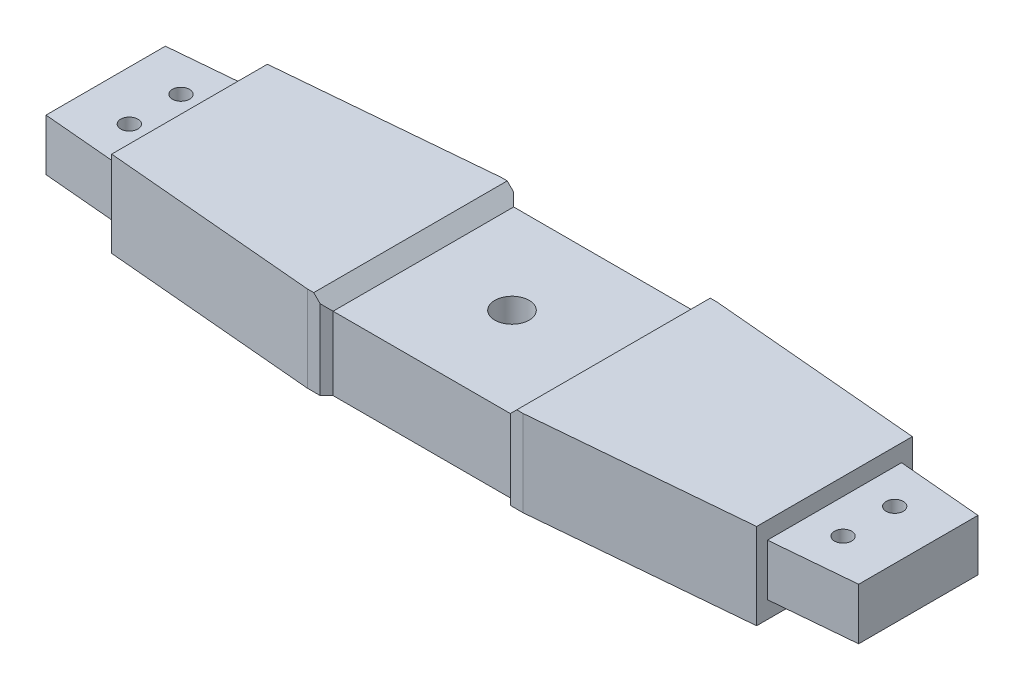
from build123d import *

# Parameters (mm, degrees)
SKETCH1_R                = 4
BOSS_EXTRUDE1_DEPTH      = 12
SKETCH2_R                = 4
BOSS_EXTRUDE2_DEPTH      = 4
BOSS_EXTRUDE2_DEPTH_BACK = 16
CUT_EXTRUDE1_DEPTH       = 1
CUT_EXTRUDE1_DEPTH_BACK  = 46
SKETCH6_R                = 2.05
CUT_EXTRUDE3_DEPTH       = 6.5
SKETCH7_R                = 2
CUT_EXTRUDE4_DEPTH       = 17
CUT_EXTRUDE5_DEPTH       = 1
CUT_EXTRUDE5_DEPTH_BACK  = 21
CUT_EXTRUDE6_DEPTH       = 17


with BuildPart() as part:
    # Sketch1 → Boss-Extrude1 (new body)
    with BuildSketch(Plane(origin=(0, 0, 0), x_dir=(1, 0, 0), z_dir=(0, 1, 0))):
        Polygon((25, 20), (-25, 20), (-95, 13.834935185), (-95, -13.834935185), (-25, -20), (25, -20), (95, -13.834935185), (95, 13.834935185), align=None)
        Circle(SKETCH1_R, mode=Mode.SUBTRACT)
    extrude(amount=BOSS_EXTRUDE1_DEPTH)

    # Sketch2 → Boss-Extrude2 (add, two sides)
    with BuildSketch(Plane(origin=(0, 12, 0), x_dir=(1, 0, 0), z_dir=(0, 1, 0))) as boss_extrude2_sk:
        Polygon((-25, 20), (-75, 15.596382275), (-75, -15.596382275), (-25, -20), (25, -20), (75, -15.596382275), (75, 15.596382275), (25, 20), align=None)
        Circle(SKETCH2_R, mode=Mode.SUBTRACT)
        Polygon((-25, -20), (-75, -15.596382275), (-75, -18.10605947), (-25.109877781, -22.5), (25.109877781, -22.5), (75, -18.10605947), (75, -15.596382275), (25, -20), align=None)
        Polygon((-25.109877781, 22.5), (-75, 18.10605947), (-75, 15.596382275), (-25, 20), (25, 20), (75, 15.596382275), (75, 18.10605947), (25.109877781, 22.5), align=None)
    extrude(amount=BOSS_EXTRUDE2_DEPTH)
    extrude(boss_extrude2_sk.sketch, amount=-BOSS_EXTRUDE2_DEPTH_BACK)

    # Sketch3 → Cut-Extrude1 (cut, two sides)
    with BuildSketch(Plane.XY.offset(22.5)) as cut_extrude1_sk:
        Polygon((23.609877781, 16), (-23.609877781, 16), (-20.609877781, 13), (20.609877781, 13), align=None)
    extrude(amount=CUT_EXTRUDE1_DEPTH, mode=Mode.SUBTRACT)
    extrude(cut_extrude1_sk.sketch, amount=-CUT_EXTRUDE1_DEPTH_BACK, mode=Mode.SUBTRACT)

    # Sketch6 → Cut-Extrude3 (cut)
    with BuildSketch(Plane(origin=(0, 0, -22.5), x_dir=(-1, 0, 0), z_dir=(0, 0, -1))):
        with Locations((-10, 4.5)):
            Circle(SKETCH6_R)
        with Locations((10, 4.5)):
            Circle(SKETCH6_R)
    extrude(amount=-CUT_EXTRUDE3_DEPTH, mode=Mode.SUBTRACT)

    # Sketch7 → Cut-Extrude4 (cut, through all)
    with BuildSketch(Plane.XZ):
        with Locations((-83, -6)):
            Circle(SKETCH7_R)
        with Locations((-83, 6)):
            Circle(SKETCH7_R)
        with Locations((83, 6)):
            Circle(SKETCH7_R)
        with Locations((83, -6)):
            Circle(SKETCH7_R)
    extrude(amount=-CUT_EXTRUDE4_DEPTH, mode=Mode.SUBTRACT)

    # Sketch8 → Cut-Extrude5 (cut, two sides)
    with BuildSketch(Plane.XZ.offset(4)) as cut_extrude5_sk:
        Polygon((-22.109877781, -22.5), (-20.609877781, -21), (20.609877781, -21), (22.109877781, -22.5), align=None)
        Polygon((-22.109877781, 22.5), (22.109877781, 22.5), (20.609877781, 21), (-20.609877781, 21), align=None)
    extrude(amount=CUT_EXTRUDE5_DEPTH, mode=Mode.SUBTRACT)
    extrude(cut_extrude5_sk.sketch, amount=-CUT_EXTRUDE5_DEPTH_BACK, mode=Mode.SUBTRACT)

    # Sketch9 → Cut-Extrude6 (cut, through all)
    with BuildSketch(Plane(origin=(0, 12, 0), x_dir=(1, 0, 0), z_dir=(0, 1, 0))):
        Polygon((-94.5, 13.878971362), (-94.5, -13.878971362), (-95, -13.834935185), (-95, 13.834935185), align=None)
        Polygon((94.5, 13.878971362), (94.5, -13.878971362), (95, -13.834935185), (95, 13.834935185), align=None)
    extrude(amount=-CUT_EXTRUDE6_DEPTH, mode=Mode.SUBTRACT)


solid = part.part
